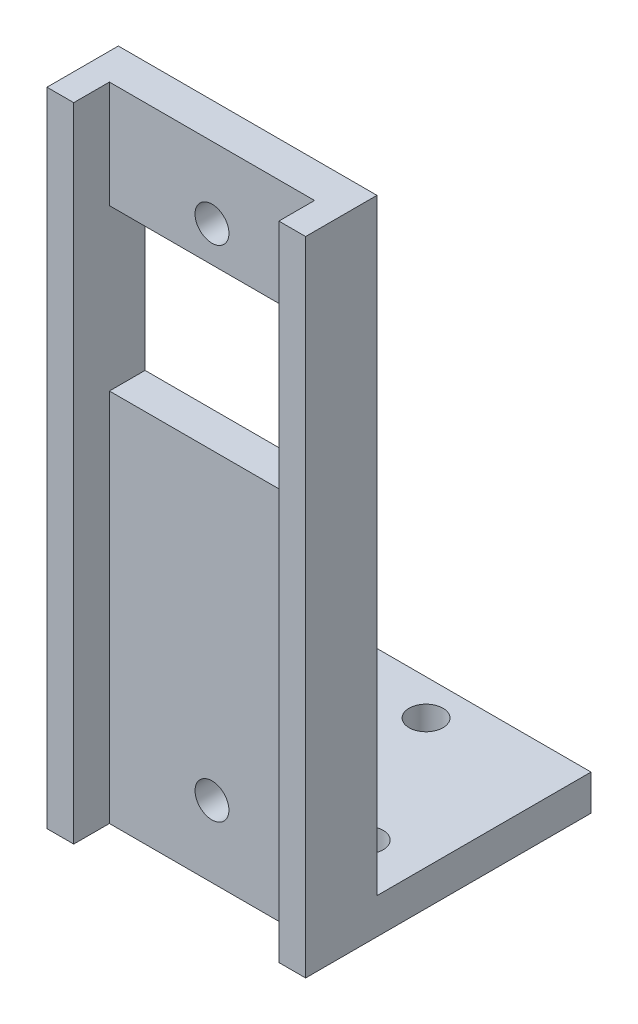
from build123d import *

# Parameters (mm, degrees)
SKETCH1_W           = 14.5
SKETCH1_H           = 36
BOSS_EXTRUDE1_DEPTH = 4
SKETCH3_W           = 14.5
SKETCH3_H           = 16
BOSS_EXTRUDE2_DEPTH = 2
SKETCH2_W           = 11.5
SKETCH2_H           = 36
CUT_EXTRUDE1_DEPTH  = 2
SKETCH4_R           = 0.95
CUT_EXTRUDE2_DEPTH  = 15
SKETCH5_W           = 11.5
SKETCH5_H           = 9
CUT_EXTRUDE3_DEPTH  = 15
SKETCH6_R           = 0.95
CUT_EXTRUDE4_DEPTH  = 3


with BuildPart() as part:
    # Sketch1 → Boss-Extrude1 (new body)
    with BuildSketch(Plane.XY):
        Rectangle(SKETCH1_W, SKETCH1_H)
    extrude(amount=BOSS_EXTRUDE1_DEPTH)

    # Sketch3 → Boss-Extrude2 (add)
    with BuildSketch(Plane.XZ.offset(18)):
        with Locations((0, -4)):
            Rectangle(SKETCH3_W, SKETCH3_H)
    extrude(amount=-BOSS_EXTRUDE2_DEPTH)

    # Sketch2 → Cut-Extrude1 (cut)
    with BuildSketch(Plane.XY.offset(4)):
        Rectangle(SKETCH2_W, SKETCH2_H)
    extrude(amount=-CUT_EXTRUDE1_DEPTH, mode=Mode.SUBTRACT)

    # Sketch4 → Cut-Extrude2 (cut, through all)
    with BuildSketch(Plane.XY.offset(2)):
        with Locations((0, -14)):
            Circle(SKETCH4_R)
        with Locations((0, 14)):
            Circle(SKETCH4_R)
    extrude(amount=-CUT_EXTRUDE2_DEPTH, mode=Mode.SUBTRACT)

    # Sketch5 → Cut-Extrude3 (cut, through all)
    with BuildSketch(Plane.XY.offset(2)):
        with Locations((0, 7.5)):
            Rectangle(SKETCH5_W, SKETCH5_H)
    extrude(amount=-CUT_EXTRUDE3_DEPTH, mode=Mode.SUBTRACT)

    # Sketch6 → Cut-Extrude4 (cut, through all)
    with BuildSketch(Plane(origin=(0, -16, 0), x_dir=(1, 0, 0), z_dir=(0, 1, 0))):
        with Locations((-4.25, 2.395194775)):
            Circle(SKETCH6_R)
        with Locations((4.25, 2.395194775)):
            Circle(SKETCH6_R)
        with Locations((0, 10)):
            Circle(SKETCH6_R)
    extrude(amount=-CUT_EXTRUDE4_DEPTH, mode=Mode.SUBTRACT)


solid = part.part
